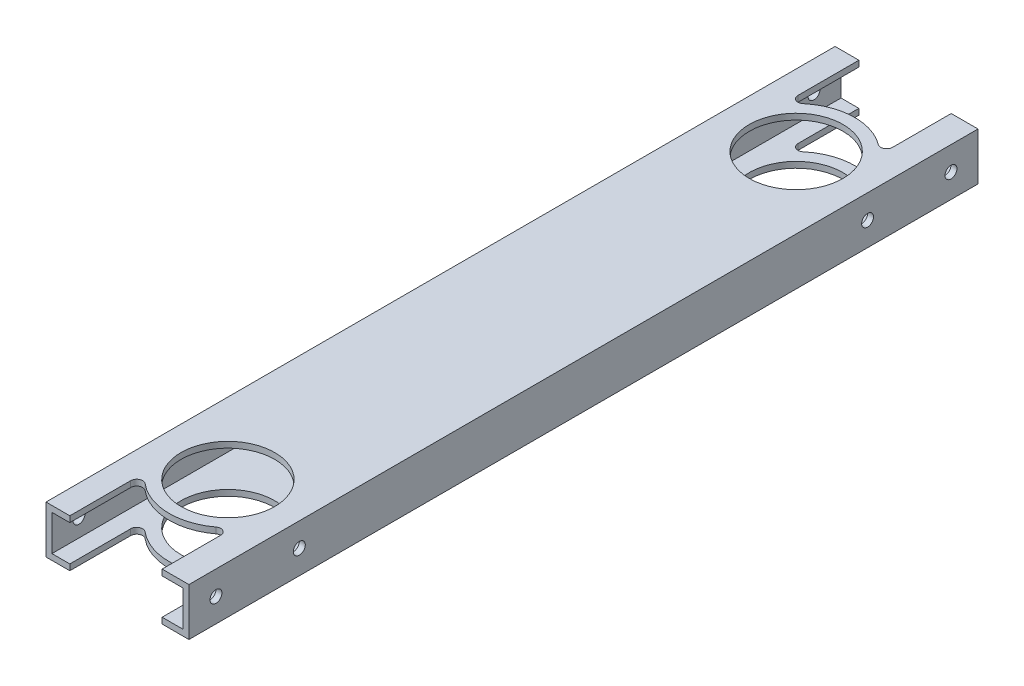
from build123d import *

# Parameters (mm, degrees)
SKETCH1_W           = 76.2
SKETCH1_H           = 25.4
SKETCH1_W_2         = 69.85
SKETCH1_H_2         = 19.05
EXTRUDE_THIN1_DEPTH = 420.69258
SKETCH4_R           = 24.97201
CUT_EXTRUDE3_DEPTH  = 26.4
CUT_EXTRUDE7_DEPTH  = 26.4
SKETCH7_R           = 3.175
CUT_EXTRUDE8_DEPTH  = 77.2
SKETCH8_R           = 3.175
CUT_EXTRUDE9_DEPTH  = 77.2


with BuildPart() as part:
    # Sketch1 → Extrude-Thin1 (new body)
    with BuildSketch(Plane.XY):
        Rectangle(SKETCH1_W, SKETCH1_H)
        Rectangle(SKETCH1_W_2, SKETCH1_H_2, mode=Mode.SUBTRACT)
    extrude(amount=EXTRUDE_THIN1_DEPTH)

    # Sketch4 → Cut-Extrude3 (cut, through all)
    with BuildSketch(Plane(origin=(0, 12.7, 0), x_dir=(1, 0, 0), z_dir=(0, 1, 0))):
        with Locations((0, -361.82808)):
            Circle(SKETCH4_R)
        with Locations((0, -58.8645)):
            Circle(SKETCH4_R)
    extrude(amount=-CUT_EXTRUDE3_DEPTH, mode=Mode.SUBTRACT)

    # Sketch6 → Cut-Extrude7 (cut, through all)
    with BuildSketch(Plane(origin=(0, 12.7, 0), x_dir=(1, 0, 0), z_dir=(0, 1, 0))):
        with BuildLine():
            Line((23.8125, 0), (-25.4, 0))
            Line((-25.4, 0), (-25.4, -32.480924163))
            ThreePointArc((-25.4, -32.480924163), (-23.564047105, -35.359739519), (-20.179478519, -34.909188331))
            ThreePointArc((-20.179478519, -34.909188331), (-0.919958513, -27.556002962), (18.738087196, -33.765647463))
            ThreePointArc((18.738087196, -33.765647463), (22.060523075, -34.059710885), (23.8125, -31.221466652))
            Line((23.8125, -31.221466652), (23.8125, 0))
        make_face()
    cut_extrude7 = extrude(amount=-CUT_EXTRUDE7_DEPTH, mode=Mode.SUBTRACT)

    # Sketch7 → Cut-Extrude8 (cut, through all)
    with BuildSketch(Plane(origin=(38.1, 0, 0), x_dir=(0, 0, -1), z_dir=(1, 0, 0))):
        with Locations((-14.4145, 0)):
            Circle(SKETCH7_R)
    cut_extrude8 = extrude(amount=-CUT_EXTRUDE8_DEPTH, mode=Mode.SUBTRACT)

    # Mirror3: Cut-Extrude7, Cut-Extrude8 across plane
    add(cut_extrude7.mirror(Plane.XY.offset(210.34629)), mode=Mode.SUBTRACT)
    add(cut_extrude8.mirror(Plane.XY.offset(210.34629)), mode=Mode.SUBTRACT)

    # Sketch8 → Cut-Extrude9 (cut, through all)
    with BuildSketch(Plane(origin=(38.1, 0, 0), x_dir=(0, 0, -1), z_dir=(1, 0, 0))):
        with Locations((-58.8645, 0)):
            Circle(SKETCH8_R)
        with Locations((-361.82808, 0)):
            Circle(SKETCH8_R)
    extrude(amount=-CUT_EXTRUDE9_DEPTH, mode=Mode.SUBTRACT)


solid = part.part
